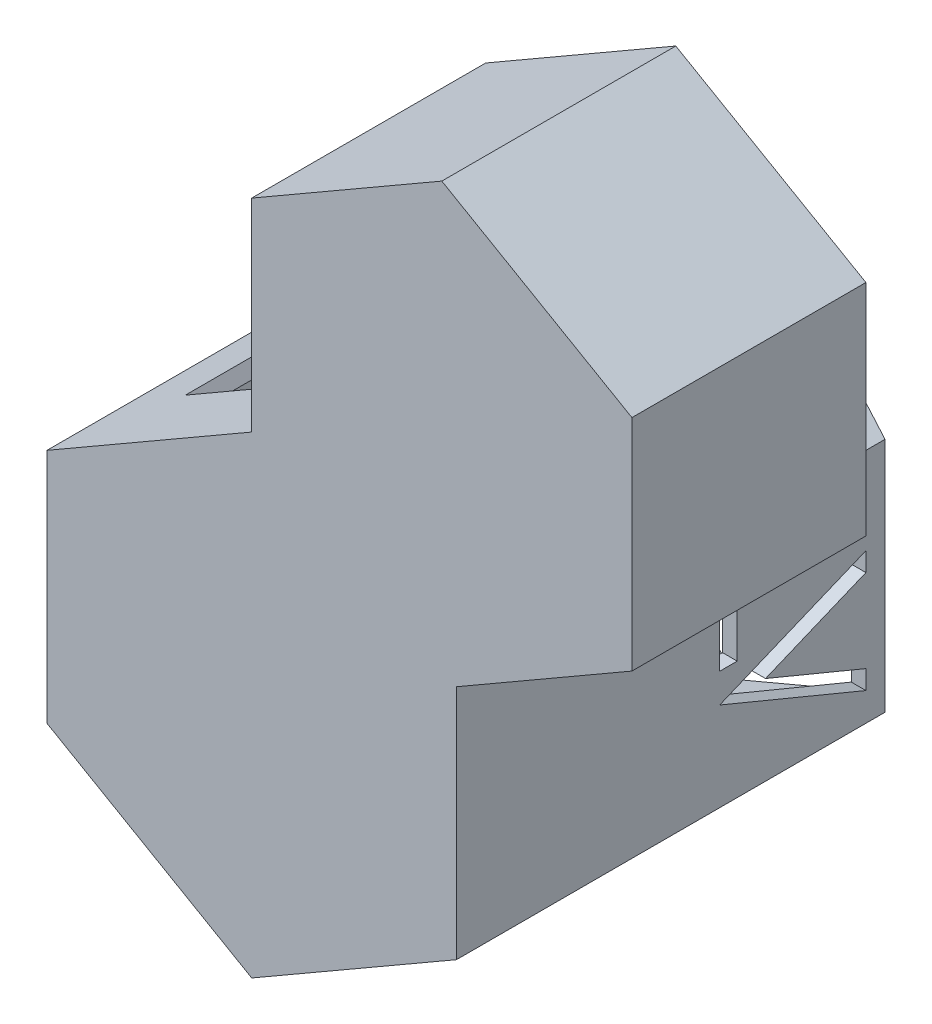
from build123d import *

# Parameters (mm, degrees)
MAIN_DEPTH           = 90
BOTTOMHOLE_DEPTH     = 3
SKETCH3_W            = 268.606603974
SKETCH3_H            = 183.988590268
PLANECUT_DEPTH       = 10
HOLE_DEPTH           = 10
CIRPATTERN1_COUNT    = 4
CIRPATTERN1_ANGLE    = 180
LOUBNAVANACKER_DEPTH = 2.5
BOSS_EXTRUDE3_DEPTH  = 40
BOSS_EXTRUDE4_DEPTH  = 3
CIRPATTERN4_COUNT    = 2
CIRPATTERN4_ANGLE    = 60


with BuildPart() as part:
    # Sketch1 → Main (new body)
    with BuildSketch(Plane.XY):
        Polygon((35, 20.207259422), (0, 40.414518843), (-35, 20.207259422), (-35, -20.207259422), (0, -40.414518843), (35, -20.207259422), align=None)
        Polygon((32.5, 18.763883749), (0, 37.527767497), (-32.5, 18.763883749), (-32.5, -18.763883749), (0, -37.527767497), (32.5, -18.763883749), align=None, mode=Mode.SUBTRACT)
    extrude(amount=MAIN_DEPTH)

    # Sketch2 → BottomHole (add)
    with BuildSketch(Plane.XY.offset(90)):
        Polygon((35, 20.207259422), (0, 40.414518843), (-35, 20.207259422), (-35, -20.207259422), (0, -40.414518843), (35, -20.207259422), align=None)
    extrude(amount=BOTTOMHOLE_DEPTH)

    # Sketch3 → PlaneCut (cut, symmetric)
    with BuildSketch(Plane(origin=(0, 0, 0), x_dir=(0, -1, 0), z_dir=(-0.258819045, 0, 0.965925826))):
        with Locations((7.882446848, -1.221649526)):
            Rectangle(SKETCH3_W, SKETCH3_H)
    extrude(amount=PLANECUT_DEPTH, both=True, mode=Mode.SUBTRACT)

    # Sketch4 → Hole (cut)
    with BuildSketch(Plane(origin=(-17.5, 30.310889132, 0), x_dir=(0.866025404, 0.5, 0), z_dir=(-0.5, 0.866025404, 0))):
        with BuildLine():
            Line((-10.207259422, -38), (-10.207259422, -78))
            Line((-10.207259422, -78), (10.207259422, -78))
            Line((10.207259422, -78), (10.207259422, -38))
            ThreePointArc((10.207259422, -38), (9.537386441, -35.5), (7.707259422, -33.669872981))
            ThreePointArc((7.707259422, -33.669872981), (6.125264739, -25.669720966), (0, -20.285830986))
            ThreePointArc((0, -20.285830986), (-6.125264739, -25.669720966), (-7.707259422, -33.669872981))
            ThreePointArc((-7.707259422, -33.669872981), (-9.537386441, -35.5), (-10.207259422, -38))
        make_face()
    hole = extrude(amount=-HOLE_DEPTH, mode=Mode.SUBTRACT)

    # CirPattern1: Hole ×4 about axis
    cirpattern1_axis = Axis((0, 0, 0), (0, 0, 1))
    for i in range(1, CIRPATTERN1_COUNT):
        add(hole.rotate(cirpattern1_axis, i * CIRPATTERN1_ANGLE / (CIRPATTERN1_COUNT - 1)), mode=Mode.SUBTRACT)

    # Sketch6 → LoubnaVanacker (cut)
    with BuildSketch(Plane(origin=(17.5, 30.310889132, 0), x_dir=(0.866025404, -0.5, 0), z_dir=(0.5, 0.866025404, 0))):
        Polygon((-12, -23), (-12, -48), (0, -48), (0, -45), (-9, -45), (-9, -23), align=None)
        Polygon((-2.108162458, -23), (5, -40.160622211), (12.108162458, -23), (15.355339059, -23), (5, -48), (-5.355339059, -23), align=None)
    loubnavanacker = extrude(amount=-LOUBNAVANACKER_DEPTH, mode=Mode.SUBTRACT)

    # Sketch7 → Boss-Extrude3 (add)
    with BuildSketch(Plane(origin=(0, 0, 93), x_dir=(-1, 0, 0), z_dir=(0, 0, -1))):
        Polygon((-65, 37.527767497), (-32.5, 18.763883749), (0, 37.527767497), (0, 75.055534995), (-32.5, 93.819418743), (-65, 75.055534995), align=None)
        Polygon((-62, 39.259818305), (-32.5, 22.227985364), (-3, 39.259818305), (-3, 73.323484187), (-32.5, 90.355317128), (-62, 73.323484187), align=None, mode=Mode.SUBTRACT)
    extrude(amount=BOSS_EXTRUDE3_DEPTH)

    # Sketch8 → Boss-Extrude4 (add)
    with BuildSketch(Plane.XY.offset(93)):
        Polygon((32.5, 93.819418743), (0, 75.055534995), (0, 37.527767497), (32.5, 18.763883749), (65, 37.527767497), (65, 75.055534995), align=None)
    extrude(amount=-BOSS_EXTRUDE4_DEPTH)

    # CirPattern4: LoubnaVanacker ×2 about axis
    cirpattern4_axis = Axis((0, 0, -3.726732928), (0, 0, -1))
    for i in range(1, CIRPATTERN4_COUNT):
        add(loubnavanacker.rotate(cirpattern4_axis, i * CIRPATTERN4_ANGLE / (CIRPATTERN4_COUNT - 1)), mode=Mode.SUBTRACT)


solid = part.part
